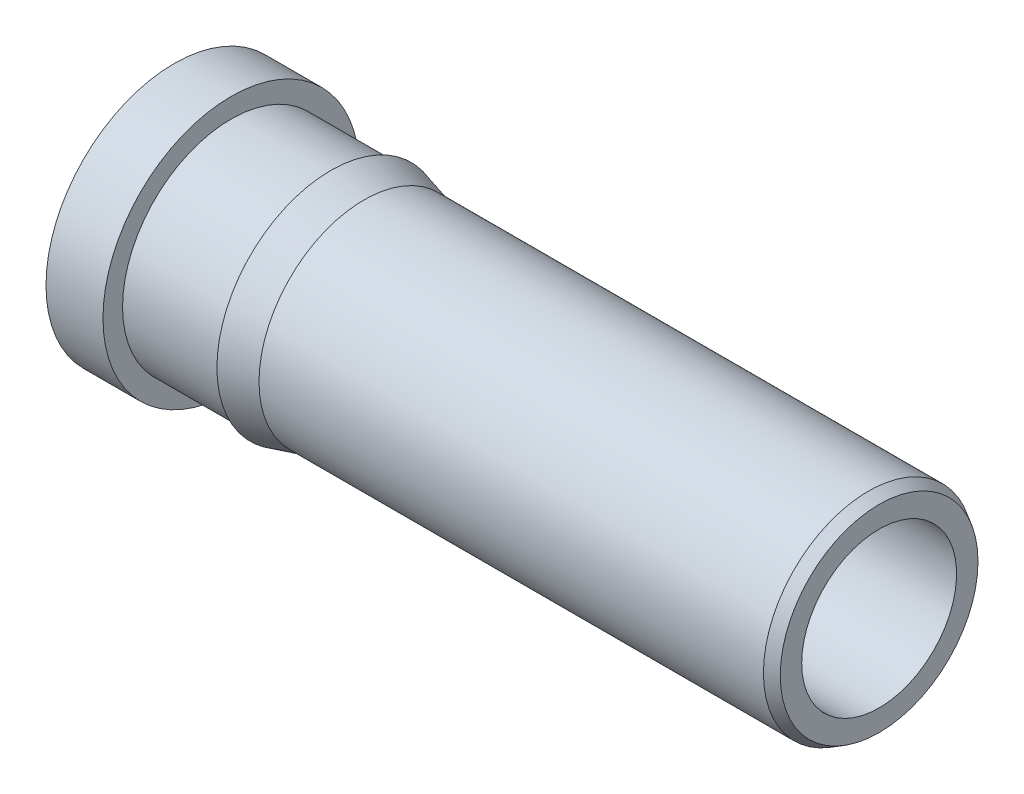
from build123d import *

# Parameters (mm, degrees)
HOLE1_D     = 1.2954
HOLE1_DEPTH = 2.3368
HOLE1_TIP   = 0.389177423
HOLE2_D     = 1.1049
HOLE2_DEPTH = 5.0292
HOLE2_TIP   = 0.331945449


with BuildPart() as part:
    # Sketch1 → RevolutionAngle1 (revolve)
    with BuildSketch(Plane.XY):
        Polygon((0, 0), (0, 0.9144), (0.4064, 0.9144), (0.4064, 0.7747), (1.1176, 0.7747), (1.1176, 0.8128), (1.354585226, 0.7493), (4.953, 0.7493), (5.0292, 0.705305909), (5.0292, 0), align=None)
    revolve(axis=Axis((0, 0, 0), (1, 0, 0)))

    # Hole1
    with Locations(Plane.ZY):
        with Locations((0, 0)):
            Hole(HOLE1_D / 2, depth=HOLE1_DEPTH)
            with Locations((0, 0, -(HOLE1_DEPTH + HOLE1_TIP / 2))):  # 118° drill point
                Cone(0, HOLE1_D / 2, HOLE1_TIP, mode=Mode.SUBTRACT)

    # Hole2
    with Locations(Plane(origin=(0, 0.341908119, -0.685195276), x_dir=(0, 0, 1), z_dir=(-1, 0, 0))):
        with Locations((0.685195276, -0.341908119)):
            Hole(HOLE2_D / 2, depth=HOLE2_DEPTH)
            with Locations((0, 0, -(HOLE2_DEPTH + HOLE2_TIP / 2))):  # 118° drill point
                Cone(0, HOLE2_D / 2, HOLE2_TIP, mode=Mode.SUBTRACT)


solid = part.part
